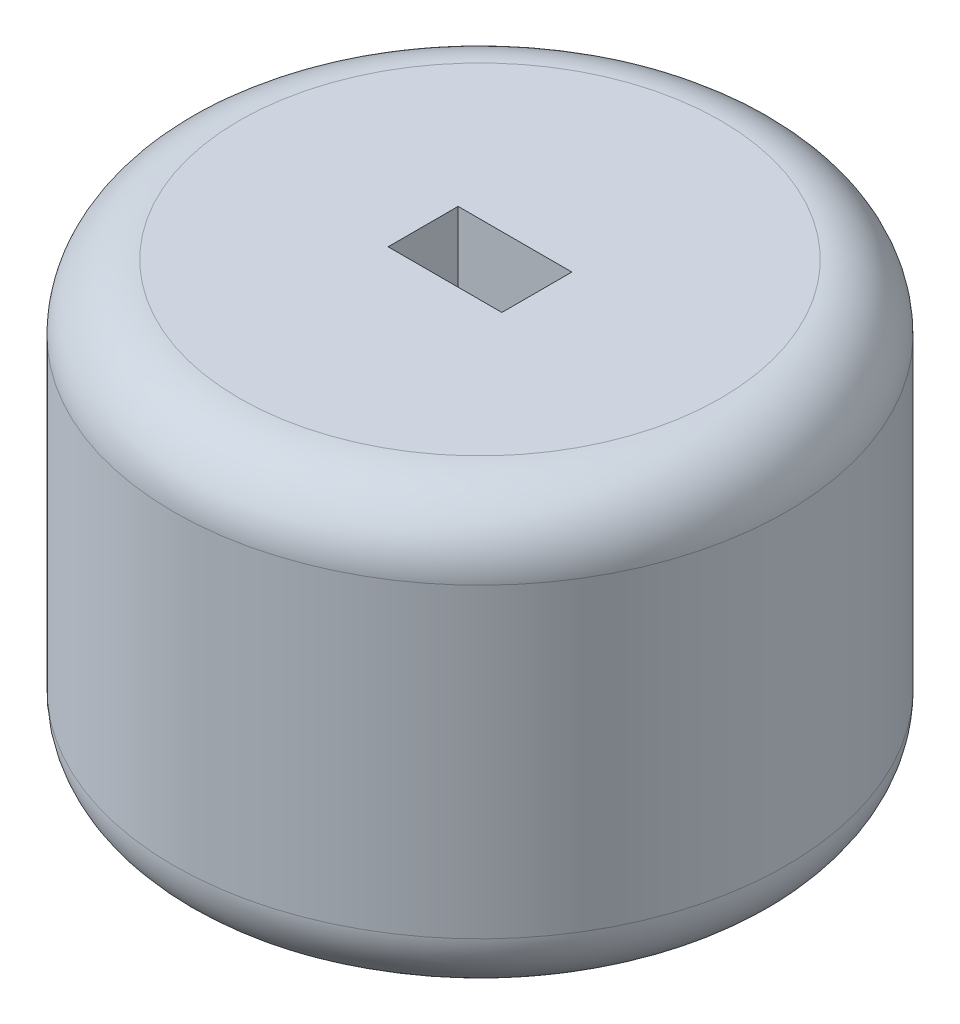
from build123d import *

# Parameters (mm, degrees)
SKETCH2_R           = 14
BOSS_EXTRUDE1_DEPTH = 20
FILLET1_R           = 3
SKETCH3_W           = 5.2
SKETCH3_H           = 3.2
CUT_EXTRUDE1_DEPTH  = 21


with BuildPart() as part:
    # Sketch2 → Boss-Extrude1 (new body)
    with BuildSketch(Plane(origin=(0, 0, 0), x_dir=(1, 0, 0), z_dir=(0, 1, 0))):
        Circle(SKETCH2_R)
    extrude(amount=BOSS_EXTRUDE1_DEPTH)

    # Fillet1
    fillet1_edges = [part.edges().sort_by_distance(p)[0] for p in [
        (-14, 0, 0),
        (-14, 20, 0),
    ]]
    fillet(fillet1_edges, radius=FILLET1_R)

    # Sketch3 → Cut-Extrude1 (cut, through all)
    with BuildSketch(Plane.XZ):
        Rectangle(SKETCH3_W, SKETCH3_H)
    extrude(amount=-CUT_EXTRUDE1_DEPTH, mode=Mode.SUBTRACT)


solid = part.part
